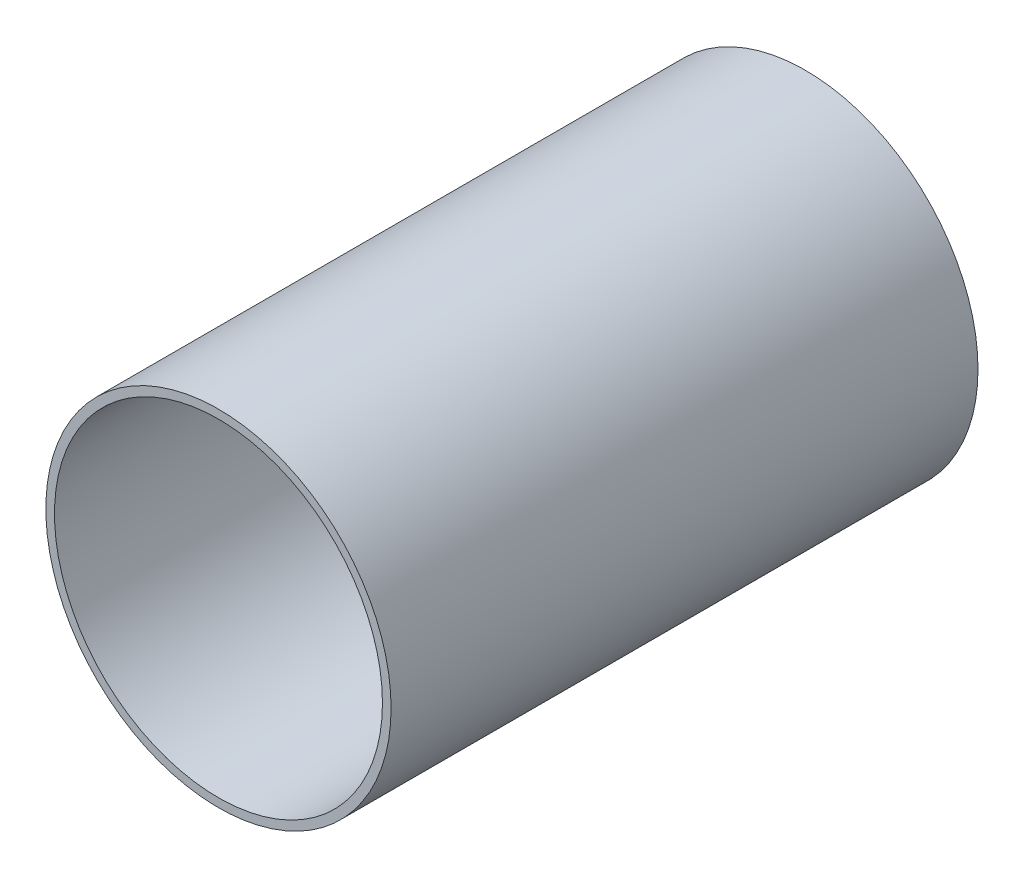
from build123d import *

# Parameters (mm, degrees)
SKETCH1_R           = 63.5
SKETCH1_R_2         = 60.325
BOSS_EXTRUDE1_DEPTH = 107.95


with BuildPart() as part:
    # Sketch1 → Boss-Extrude1 (new body, symmetric)
    with BuildSketch(Plane.XY):
        Circle(SKETCH1_R)
        Circle(SKETCH1_R_2, mode=Mode.SUBTRACT)
    extrude(amount=BOSS_EXTRUDE1_DEPTH, both=True)


solid = part.part
